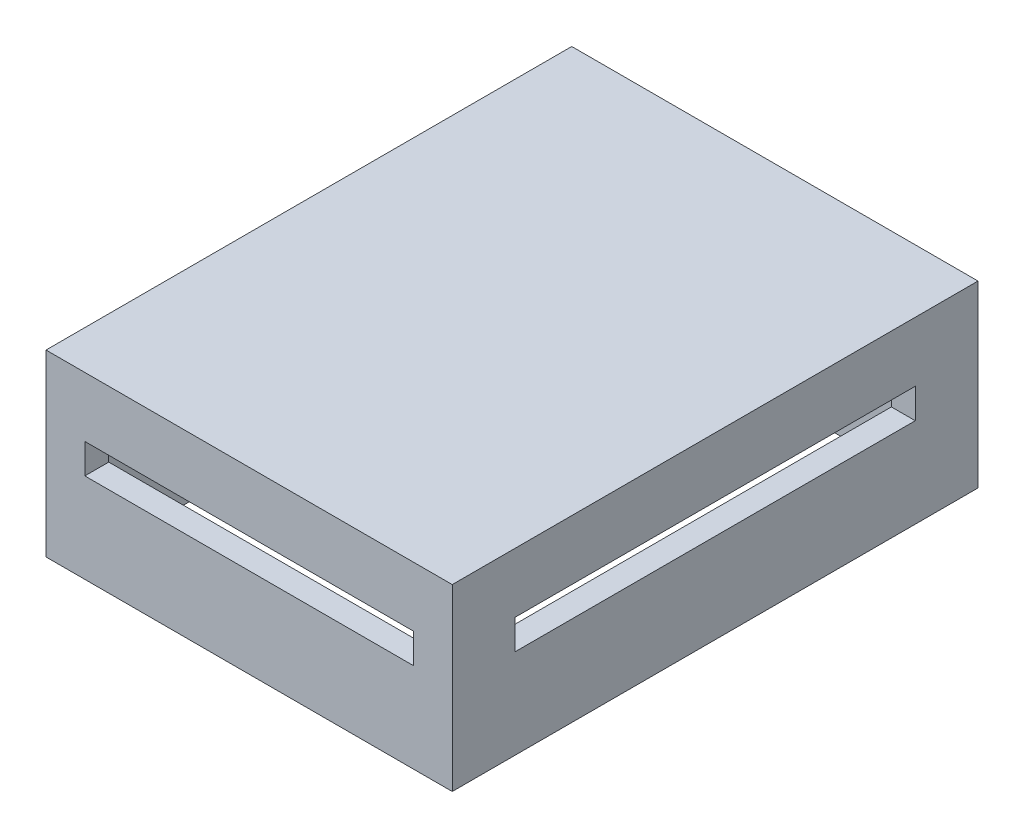
from build123d import *

# Parameters (mm, degrees)
CROQUIS1_W              = 68
CROQUIS1_H              = 88
CROQUIS1_W_2            = 60
CROQUIS1_H_2            = 80
SALIENTE_EXTRUIR1_DEPTH = 27
CROQUIS3_W              = 68
CROQUIS3_H              = 88
SALIENTE_EXTRUIR2_DEPTH = 3
CROQUIS4_W              = 67
CROQUIS4_H              = 5
CORTAR_EXTRUIR1_DEPTH   = 69
CROQUIS5_W              = 55
CROQUIS5_H              = 5
CORTAR_EXTRUIR2_DEPTH   = 89


with BuildPart() as part:
    # Croquis1 → Saliente-Extruir1 (new body)
    with BuildSketch(Plane(origin=(0, 0, 0), x_dir=(1, 0, 0), z_dir=(0, 1, 0))):
        with Locations((30, 40)):
            Rectangle(CROQUIS1_W, CROQUIS1_H)
        with Locations((30, 40)):
            Rectangle(CROQUIS1_W_2, CROQUIS1_H_2, mode=Mode.SUBTRACT)
    extrude(amount=SALIENTE_EXTRUIR1_DEPTH)

    # Croquis3 → Saliente-Extruir2 (add)
    with BuildSketch(Plane(origin=(0, 27, 0), x_dir=(1, 0, 0), z_dir=(0, 1, 0))):
        with Locations((30, 40)):
            Rectangle(CROQUIS3_W, CROQUIS3_H)
    extrude(amount=SALIENTE_EXTRUIR2_DEPTH)

    # Croquis4 → Cortar-Extruir1 (cut, through all)
    with BuildSketch(Plane.ZY.offset(4)):
        with Locations((-40, 17.5)):
            Rectangle(CROQUIS4_W, CROQUIS4_H)
    extrude(amount=-CORTAR_EXTRUIR1_DEPTH, mode=Mode.SUBTRACT)

    # Croquis5 → Cortar-Extruir2 (cut, through all)
    with BuildSketch(Plane.XY.offset(4)):
        with Locations((30, 17.5)):
            Rectangle(CROQUIS5_W, CROQUIS5_H)
    extrude(amount=-CORTAR_EXTRUIR2_DEPTH, mode=Mode.SUBTRACT)


solid = part.part
